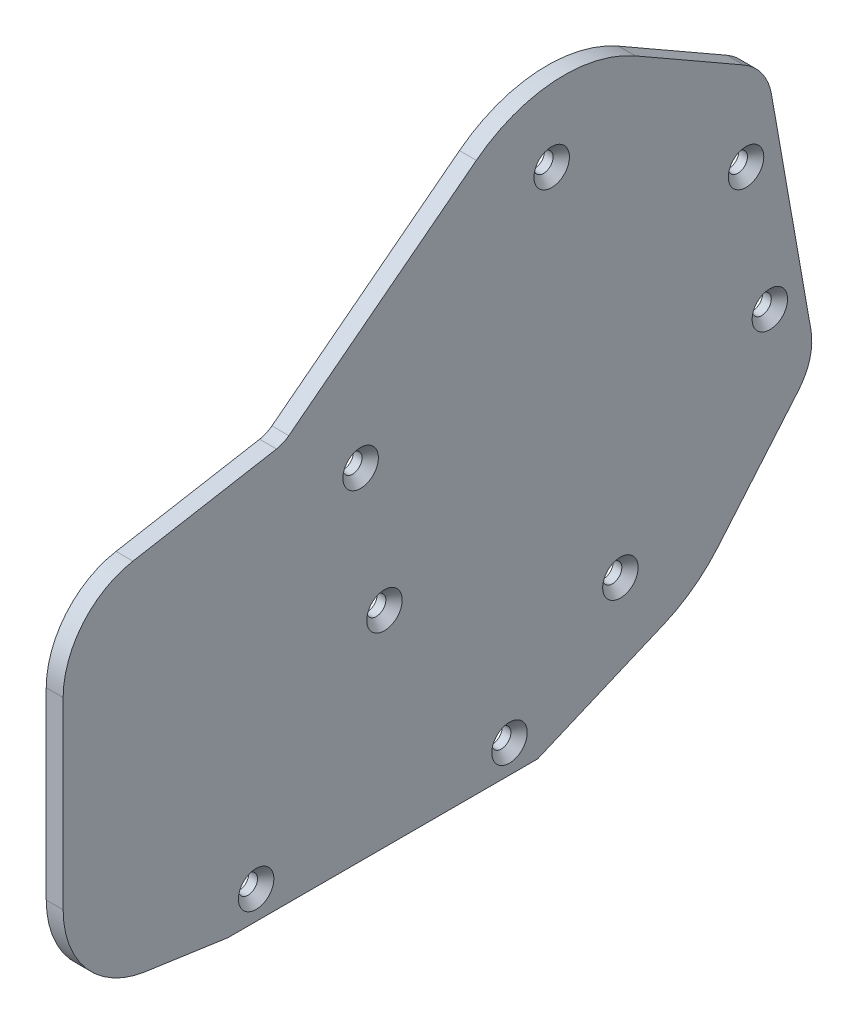
from build123d import *

# Parameters (mm, degrees)
BOSS_EXTRUDE1_DEPTH                            = 3
CSK_FOR_M3_FLAT_HEAD_MACHINE_SCREW1_AT_2_COUNT = 2
CSK_FOR_M3_FLAT_HEAD_MACHINE_SCREW1_AT_2_PITCH = 24.36335345
CSK_FOR_M3_FLAT_HEAD_MACHINE_SCREW1_AT_3_COUNT = 2
CSK_FOR_M3_FLAT_HEAD_MACHINE_SCREW1_AT_3_PITCH = 69.5
CSK_FOR_M3_FLAT_HEAD_MACHINE_SCREW1_AT_4_COUNT = 2
CSK_FOR_M3_FLAT_HEAD_MACHINE_SCREW1_AT_4_PITCH = 73.646608824
CSK_FOR_M3_FLAT_HEAD_MACHINE_SCREW1_AT_5_COUNT = 2
CSK_FOR_M3_FLAT_HEAD_MACHINE_SCREW1_AT_5_PITCH = 56.579922425
CSK_FOR_M3_FLAT_HEAD_MACHINE_SCREW1_AT_6_COUNT = 2
CSK_FOR_M3_FLAT_HEAD_MACHINE_SCREW1_AT_6_PITCH = 38.581652039
CSK_FOR_M3_FLAT_HEAD_MACHINE_SCREW1_AT_7_COUNT = 2
CSK_FOR_M3_FLAT_HEAD_MACHINE_SCREW1_AT_7_PITCH = 110.143173396
CSK_FOR_M3_FLAT_HEAD_MACHINE_SCREW1_AT_8_COUNT = 2
CSK_FOR_M3_FLAT_HEAD_MACHINE_SCREW1_AT_8_PITCH = 79.535664399


with BuildPart() as part:
    # Sketch2 → Boss-Extrude1 (new body)
    with BuildSketch(Plane(origin=(29, 0, 0), x_dir=(0, 0, -1), z_dir=(1, 0, 0))):
        with BuildLine():
            Line((-16.691511003, 108.816260881), (16.610141275, 134.506640075))
            ThreePointArc((16.610141275, 134.506640075), (30.439693581, 139.756494337), (44.856843921, 136.445412513))
            Line((44.856843921, 136.445412513), (64.147238229, 125.399811115))
            ThreePointArc((64.147238229, 125.399811115), (67.359474123, 122.47213667), (69.026291478, 118.458228724))
            Line((69.026291478, 118.458228724), (76.03531425, 78.708085309))
            ThreePointArc((76.03531425, 78.708085309), (75.841855651, 74.366160521), (73.824664919, 70.516397068))
            Line((73.824664919, 70.516397068), (59.475441909, 53.539223516))
            ThreePointArc((59.475441909, 53.539223516), (55.128189361, 49.472265428), (49.95644752, 46.524072909))
            Line((49.95644752, 46.524072909), (27.5, 37))
            Line((27.5, 37), (-27.5, 37))
            Line((-27.5, 37), (-42.183846688, 39.106824497))
            ThreePointArc((-42.183846688, 39.106824497), (-52.615538646, 44.799981854), (-56.769427994, 55.934497609))
            Line((-56.769427994, 55.934497609), (-56.769427994, 88.583208534))
            ThreePointArc((-56.769427994, 88.583208534), (-53.260094641, 98.225022679), (-44.374150659, 103.355324829))
            Line((-44.374150659, 103.355324829), (-18.877327121, 107.851102741))
            ThreePointArc((-18.877327121, 107.851102741), (-17.725917606, 108.201192201), (-16.691511003, 108.816260881))
        make_face()
    extrude(amount=BOSS_EXTRUDE1_DEPTH)

    # Sketch4 → CSK for M3 Flat Head Machine Screw1 (revolve, cut)
    with BuildSketch(Plane(origin=(32, 109.537877634, -64.506630382), x_dir=(0, 0, -1), z_dir=(0, 1, 0))):
        Polygon((0, 0), (0, 3), (1.7, 3), (1.7, 1.45), (3.15, 0), align=None)
    csk_for_m3_flat_head_machine_screw1 = revolve(axis=Axis((38.35, 109.537877634, -64.506630382), (-1, 0, 0)), mode=Mode.SUBTRACT)

    # CSK for M3 Flat Head Machine Screw1 at 2: CSK for M3 Flat Head Machine Screw1 ×2
    with Locations(*[Vector(0, -0.984807753, -0.173648178) * (i * CSK_FOR_M3_FLAT_HEAD_MACHINE_SCREW1_AT_2_PITCH) for i in range(1, CSK_FOR_M3_FLAT_HEAD_MACHINE_SCREW1_AT_2_COUNT)]):
        add(csk_for_m3_flat_head_machine_screw1, mode=Mode.SUBTRACT)

    # CSK for M3 Flat Head Machine Screw1 at 3: CSK for M3 Flat Head Machine Screw1 ×2
    with Locations(*[Vector(0, -0.173648178, 0.984807753) * (i * CSK_FOR_M3_FLAT_HEAD_MACHINE_SCREW1_AT_3_PITCH) for i in range(1, CSK_FOR_M3_FLAT_HEAD_MACHINE_SCREW1_AT_3_COUNT)]):
        add(csk_for_m3_flat_head_machine_screw1, mode=Mode.SUBTRACT)

    # CSK for M3 Flat Head Machine Screw1 at 4: CSK for M3 Flat Head Machine Screw1 ×2
    with Locations(*[Vector(0, -0.489659582, 0.871913696) * (i * CSK_FOR_M3_FLAT_HEAD_MACHINE_SCREW1_AT_4_PITCH) for i in range(1, CSK_FOR_M3_FLAT_HEAD_MACHINE_SCREW1_AT_4_COUNT)]):
        add(csk_for_m3_flat_head_machine_screw1, mode=Mode.SUBTRACT)

    # CSK for M3 Flat Head Machine Screw1 at 5: CSK for M3 Flat Head Machine Screw1 ×2
    with Locations(*[Vector(0, -0.918977854, 0.394309147) * (i * CSK_FOR_M3_FLAT_HEAD_MACHINE_SCREW1_AT_5_PITCH) for i in range(1, CSK_FOR_M3_FLAT_HEAD_MACHINE_SCREW1_AT_5_COUNT)]):
        add(csk_for_m3_flat_head_machine_screw1, mode=Mode.SUBTRACT)

    # CSK for M3 Flat Head Machine Screw1 at 6: CSK for M3 Flat Head Machine Screw1 ×2
    with Locations(*[Vector(0, 0.446748348, 0.894659663) * (i * CSK_FOR_M3_FLAT_HEAD_MACHINE_SCREW1_AT_6_PITCH) for i in range(1, CSK_FOR_M3_FLAT_HEAD_MACHINE_SCREW1_AT_6_COUNT)]):
        add(csk_for_m3_flat_head_machine_screw1, mode=Mode.SUBTRACT)

    # CSK for M3 Flat Head Machine Screw1 at 7: CSK for M3 Flat Head Machine Screw1 ×2
    with Locations(*[Vector(0, -0.613182602, 0.789941198) * (i * CSK_FOR_M3_FLAT_HEAD_MACHINE_SCREW1_AT_7_PITCH) for i in range(1, CSK_FOR_M3_FLAT_HEAD_MACHINE_SCREW1_AT_7_COUNT)]):
        add(csk_for_m3_flat_head_machine_screw1, mode=Mode.SUBTRACT)

    # CSK for M3 Flat Head Machine Screw1 at 8: CSK for M3 Flat Head Machine Screw1 ×2
    with Locations(*[Vector(0, -0.849152115, 0.528148356) * (i * CSK_FOR_M3_FLAT_HEAD_MACHINE_SCREW1_AT_8_PITCH) for i in range(1, CSK_FOR_M3_FLAT_HEAD_MACHINE_SCREW1_AT_8_COUNT)]):
        add(csk_for_m3_flat_head_machine_screw1, mode=Mode.SUBTRACT)


solid = part.part
